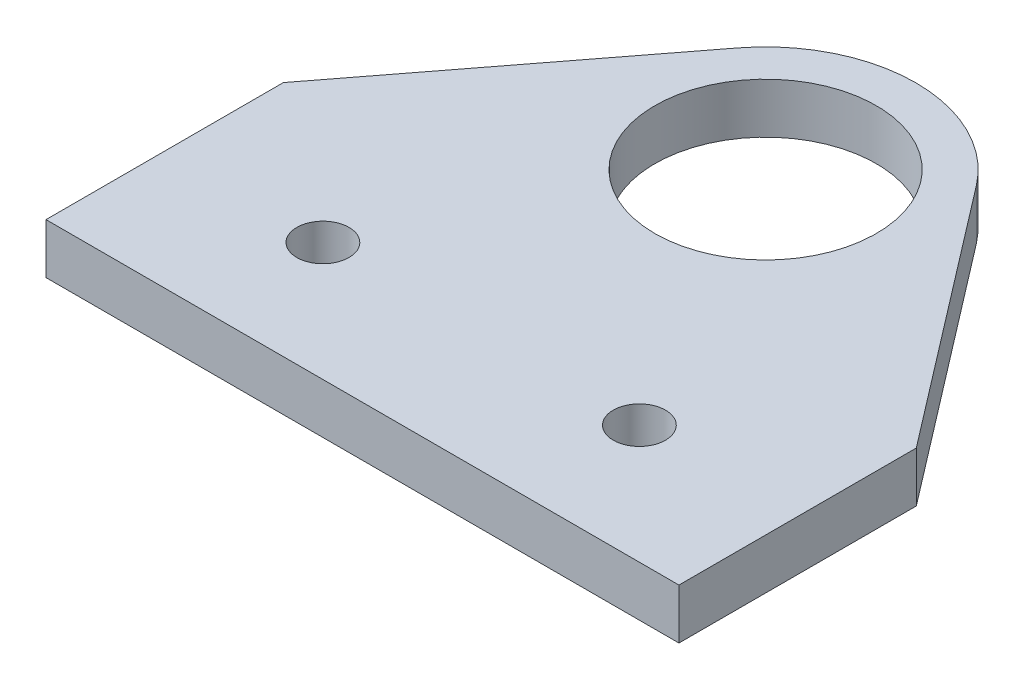
from build123d import *

# Parameters (mm, degrees)
SKETCH1_R            = 14
BOSS_EXTRUDE1_DEPTH  = 6.35
M6_CLEARANCE_HOLE1_D = 6.6


with BuildPart() as part:
    # Sketch1 → Boss-Extrude1 (new body)
    with BuildSketch(Plane(origin=(0, 0, 0), x_dir=(1, 0, 0), z_dir=(0, 1, 0))):
        with BuildLine():
            Line((40, -15), (40, 15))
            Line((40, 15), (15.079194307, 47.509320873))
            ThreePointArc((15.079194307, 47.509320873), (0, 54.95), (-15.079194307, 47.509320873))
            Line((-15.079194307, 47.509320873), (-40, 15))
            Line((-40, 15), (-40, -15))
            Line((-40, -15), (40, -15))
        make_face()
        with Locations((0, 35.95)):
            Circle(SKETCH1_R, mode=Mode.SUBTRACT)
    extrude(amount=BOSS_EXTRUDE1_DEPTH)

    # M6 Clearance Hole1 (through all)
    with Locations(Plane(origin=(0, 6.35, 0), x_dir=(1, 0, 0), z_dir=(0, 1, 0))):
        with Locations((-20, 0), (20, 0)):
            Hole(M6_CLEARANCE_HOLE1_D / 2)


solid = part.part
